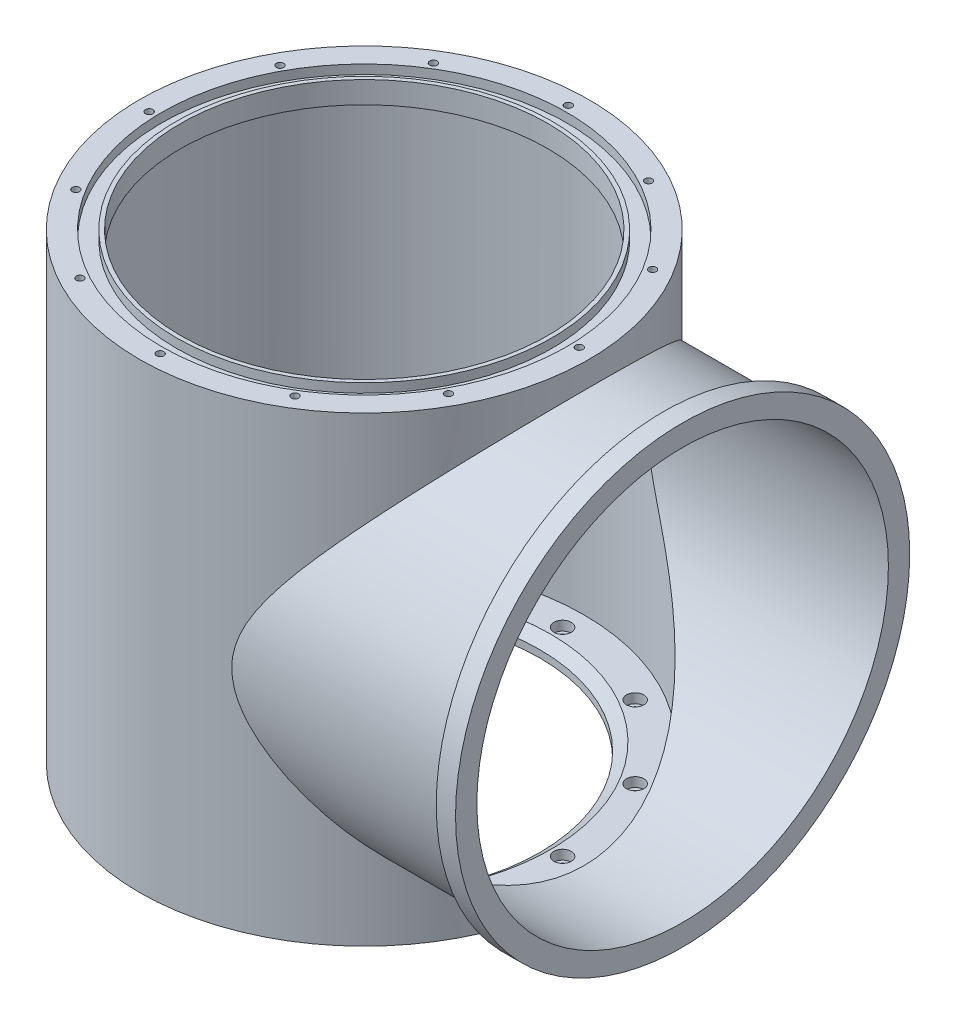
from build123d import *

# Parameters (mm, degrees)
SKETCH1_R                                            = 142.24
SKETCH1_R_2                                          = 139.065
BOSS_EXTRUDE1_DEPTH                                  = 292.1
SKETCH2_R                                            = 133.3373
SKETCH2_R_2                                          = 130.175
BOSS_EXTRUDE2_DEPTH                                  = 201.422
SKETCH1_3_R                                          = 139.065
CUT_EXTRUDE1_DEPTH                                   = 293.1000001
SKETCH2_2_R                                          = 130.175
CUT_EXTRUDE2_DEPTH                                   = 202.4220001
SKETCH3_R                                            = 143.66875
SKETCH3_R_2                                          = 133.3373
BOSS_EXTRUDE3_DEPTH                                  = 12.192
SKETCH5_R                                            = 139.065
SKETCH5_R_2                                          = 111.125
SKETCH5_R_3                                          = 2.9972
BOSS_EXTRUDE5_DEPTH                                  = 11.43
SKETCH4_R                                            = 139.065
SKETCH4_R_2                                          = 2.3368
SKETCH4_R_3                                          = 116.205
SKETCH4_R_4                                          = 128.27
SKETCH4_R_5                                          = 118.745
BOSS_EXTRUDE4_DEPTH                                  = 13.8176
SKETCH4_3_R                                          = 2.3368
CUT_EXTRUDE3_DEPTH                                   = 7.62
SKETCH4_4_R                                          = 128.27
SKETCH4_4_R_2                                        = 118.745
CUT_EXTRUDE4_DEPTH                                   = 5.7912
CBORE_FOR_M6_HEXAGON_SOCKET_HEAD_CAP_SCR_D           = 6.4
CBORE_FOR_M6_HEXAGON_SOCKET_HEAD_CAP_SCR_DEPTH       = 11.83005
CBORE_FOR_M6_HEXAGON_SOCKET_HEAD_CAP_SCR_CBORE_D     = 11
CBORE_FOR_M6_HEXAGON_SOCKET_HEAD_CAP_SCR_CBORE_DEPTH = 6
SKETCH7_W                                            = 1.27
SKETCH7_H                                            = 7.7216
CHAMFER1_SIZE                                        = 5.08
CHAMFER1_SIZE2                                       = 6.858
SKETCH5_3_R                                          = 116.6622
SKETCH5_3_R_2                                        = 111.125
CUT_EXTRUDE5_DEPTH                                   = 1.778


with BuildPart() as part:
    # Sketch1 → Boss-Extrude1 (new body)
    with BuildSketch(Plane(origin=(0, 0, 0), x_dir=(1, 0, 0), z_dir=(0, 1, 0))):
        with Locations(Location((0, 0, 0), (0, 0, 270))):  # turned: the seam where the file's is
            Circle(SKETCH1_R)
        with Locations(Location((0, 0, 0), (0, 0, 270))):  # turned: the seam where the file's is
            Circle(SKETCH1_R_2, mode=Mode.SUBTRACT)
    extrude(amount=BOSS_EXTRUDE1_DEPTH)

    # Sketch2 → Boss-Extrude2 (add)
    with BuildSketch(Plane(origin=(0, 0, 0), x_dir=(0, 0, -1), z_dir=(1, 0, 0))):
        with Locations(Location((0, 143.2687, 0), (0, 0, 180))):  # turned: the seam where the file's is
            Circle(SKETCH2_R)
        with Locations(Location((0, 143.2687, 0), (0, 0, 180))):  # turned: the seam where the file's is
            Circle(SKETCH2_R_2, mode=Mode.SUBTRACT)
    extrude(amount=BOSS_EXTRUDE2_DEPTH)

    # Sketch1_3 → Cut-Extrude1 (cut, through all)
    with BuildSketch(Plane(origin=(0, 0, 0), x_dir=(1, 0, 0), z_dir=(0, 1, 0))):
        with Locations(Location((0, 0, 0), (0, 0, 270))):  # turned: the seam where the file's is
            Circle(SKETCH1_3_R)
    extrude(amount=CUT_EXTRUDE1_DEPTH, mode=Mode.SUBTRACT)

    # Sketch2_2 → Cut-Extrude2 (cut, through all)
    with BuildSketch(Plane(origin=(0, 0, 0), x_dir=(0, 0, -1), z_dir=(1, 0, 0))):
        with Locations(Location((0, 143.2687, 0), (0, 0, 180))):  # turned: the seam where the file's is
            Circle(SKETCH2_2_R)
    extrude(amount=CUT_EXTRUDE2_DEPTH, mode=Mode.SUBTRACT)

    # Sketch3 → Boss-Extrude3 (add)
    with BuildSketch(Plane(origin=(201.422, 0, 0), x_dir=(0, 0, -1), z_dir=(1, 0, 0))):
        with Locations((0, 143.2687)):
            Circle(SKETCH3_R)
        with Locations(Location((0, 143.2687, 0), (0, 0, 180))):  # turned: the seam where the file's is
            Circle(SKETCH3_R_2, mode=Mode.SUBTRACT)
    extrude(amount=-BOSS_EXTRUDE3_DEPTH)

    # Sketch5 → Boss-Extrude5 (add)
    with BuildSketch(Plane.XZ):
        with Locations(Location((0, 0, 0), (0, 0, 270))):  # turned: the seam where the file's is
            Circle(SKETCH5_R)
        with Locations(Location((0, 0, 0), (0, 0, 270))):  # turned: the seam where the file's is
            Circle(SKETCH5_R_2, mode=Mode.SUBTRACT)
        with Locations(Location((125.476, 0, 0), (0, 0, 270))):  # turned: the seam where the file's is
            Circle(SKETCH5_R_3, mode=Mode.SUBTRACT)
        with Locations(Location((108.665403565, -62.738, 0), (0, 0, 270))):  # turned: the seam where the file's is
            Circle(SKETCH5_R_3, mode=Mode.SUBTRACT)
        with Locations(Location((62.738, -108.665403565, 0), (0, 0, 270))):  # turned: the seam where the file's is
            Circle(SKETCH5_R_3, mode=Mode.SUBTRACT)
        with Locations(Location((0, -125.476, 0), (0, 0, 270))):  # turned: the seam where the file's is
            Circle(SKETCH5_R_3, mode=Mode.SUBTRACT)
        with Locations(Location((-62.738, -108.665403565, 0), (0, 0, 270))):  # turned: the seam where the file's is
            Circle(SKETCH5_R_3, mode=Mode.SUBTRACT)
        with Locations(Location((-108.665403565, -62.738, 0), (0, 0, 270))):  # turned: the seam where the file's is
            Circle(SKETCH5_R_3, mode=Mode.SUBTRACT)
        with Locations(Location((-125.476, 0, 0), (0, 0, 270))):  # turned: the seam where the file's is
            Circle(SKETCH5_R_3, mode=Mode.SUBTRACT)
        with Locations(Location((-108.665403565, 62.738, 0), (0, 0, 270))):  # turned: the seam where the file's is
            Circle(SKETCH5_R_3, mode=Mode.SUBTRACT)
        with Locations(Location((-62.738, 108.665403565, 0), (0, 0, 270))):  # turned: the seam where the file's is
            Circle(SKETCH5_R_3, mode=Mode.SUBTRACT)
        with Locations(Location((0, 125.476, 0), (0, 0, 270))):  # turned: the seam where the file's is
            Circle(SKETCH5_R_3, mode=Mode.SUBTRACT)
        with Locations(Location((62.738, 108.665403565, 0), (0, 0, 270))):  # turned: the seam where the file's is
            Circle(SKETCH5_R_3, mode=Mode.SUBTRACT)
        with Locations(Location((108.665403565, 62.738, 0), (0, 0, 270))):  # turned: the seam where the file's is
            Circle(SKETCH5_R_3, mode=Mode.SUBTRACT)
    extrude(amount=-BOSS_EXTRUDE5_DEPTH)

    # Sketch4 → Boss-Extrude4 (add)
    with BuildSketch(Plane(origin=(0, 292.1, 0), x_dir=(1, 0, 0), z_dir=(0, 1, 0))):
        with Locations(Location((0, 0, 0), (0, 0, 90))):  # turned: the seam where the file's is
            Circle(SKETCH4_R)
        with Locations((113.088606752, 69.300787348)):
            Circle(SKETCH4_R_2, mode=Mode.SUBTRACT)
        with Locations((63.287212652, 116.560545721)):
            Circle(SKETCH4_R_2, mode=Mode.SUBTRACT)
        with Locations((-3.471938969, 132.588)):
            Circle(SKETCH4_R_2, mode=Mode.SUBTRACT)
        with Locations((-69.300787348, 113.088606752)):
            Circle(SKETCH4_R_2, mode=Mode.SUBTRACT)
        with Locations((-116.560545721, 63.287212652)):
            Circle(SKETCH4_R_2, mode=Mode.SUBTRACT)
        with Locations((-132.588, -3.471938969)):
            Circle(SKETCH4_R_2, mode=Mode.SUBTRACT)
        with Locations((-113.088606752, -69.300787348)):
            Circle(SKETCH4_R_2, mode=Mode.SUBTRACT)
        with Locations((-63.287212652, -116.560545721)):
            Circle(SKETCH4_R_2, mode=Mode.SUBTRACT)
        with Locations((3.471938969, -132.588)):
            Circle(SKETCH4_R_2, mode=Mode.SUBTRACT)
        with Locations((69.300787348, -113.088606752)):
            Circle(SKETCH4_R_2, mode=Mode.SUBTRACT)
        with Locations((116.560545721, -63.287212652)):
            Circle(SKETCH4_R_2, mode=Mode.SUBTRACT)
        with Locations((132.588, 3.471938969)):
            Circle(SKETCH4_R_2, mode=Mode.SUBTRACT)
        with Locations(Location((0, 0, 0), (0, 0, 270))):  # turned: the seam where the file's is
            Circle(SKETCH4_R_3, mode=Mode.SUBTRACT)
        with Locations((-116.560545721, 63.287212652)):
            Circle(SKETCH4_R_2)
        with Locations((-3.471938969, 132.588)):
            Circle(SKETCH4_R_2)
        with Locations((63.287212652, 116.560545721)):
            Circle(SKETCH4_R_2)
        with Locations((132.588, 3.471938969)):
            Circle(SKETCH4_R_2)
        with Locations((-132.588, -3.471938969)):
            Circle(SKETCH4_R_2)
        with Locations((-63.287212652, -116.560545721)):
            Circle(SKETCH4_R_2)
        with Locations((3.471938969, -132.588)):
            Circle(SKETCH4_R_2)
        with Locations((116.560545721, -63.287212652)):
            Circle(SKETCH4_R_2)
        Circle(SKETCH4_R_4)
        Circle(SKETCH4_R_5, mode=Mode.SUBTRACT)
        Circle(SKETCH4_R_5)
        with Locations(Location((0, 0, 0), (0, 0, 270))):  # turned: the seam where the file's is
            Circle(SKETCH4_R_3, mode=Mode.SUBTRACT)
        with Locations((69.300787348, -113.088606752)):
            Circle(SKETCH4_R_2)
        with Locations((-113.088606752, -69.300787348)):
            Circle(SKETCH4_R_2)
        with Locations((113.088606752, 69.300787348)):
            Circle(SKETCH4_R_2)
        with Locations((-69.300787348, 113.088606752)):
            Circle(SKETCH4_R_2)
    extrude(amount=-BOSS_EXTRUDE4_DEPTH)

    # Sketch4_3 → Cut-Extrude3 (cut)
    with BuildSketch(Plane(origin=(0, 292.1, 0), x_dir=(1, 0, 0), z_dir=(0, 1, 0))):
        with Locations(Location((-116.560545721, 63.287212652, 0), (0, 0, 270))):  # turned: the seam where the file's is
            Circle(SKETCH4_3_R)
        with Locations(Location((-69.300787348, 113.088606752, 0), (0, 0, 270))):  # turned: the seam where the file's is
            Circle(SKETCH4_3_R)
        with Locations(Location((-3.471938969, 132.588, 0), (0, 0, 270))):  # turned: the seam where the file's is
            Circle(SKETCH4_3_R)
        with Locations(Location((63.287212652, 116.560545721, 0), (0, 0, 270))):  # turned: the seam where the file's is
            Circle(SKETCH4_3_R)
        with Locations(Location((113.088606752, 69.300787348, 0), (0, 0, 270))):  # turned: the seam where the file's is
            Circle(SKETCH4_3_R)
        with Locations(Location((132.588, 3.471938969, 0), (0, 0, 270))):  # turned: the seam where the file's is
            Circle(SKETCH4_3_R)
        with Locations(Location((116.560545721, -63.287212652, 0), (0, 0, 270))):  # turned: the seam where the file's is
            Circle(SKETCH4_3_R)
        with Locations(Location((69.300787348, -113.088606752, 0), (0, 0, 270))):  # turned: the seam where the file's is
            Circle(SKETCH4_3_R)
        with Locations(Location((3.471938969, -132.588, 0), (0, 0, 270))):  # turned: the seam where the file's is
            Circle(SKETCH4_3_R)
        with Locations(Location((-63.287212652, -116.560545721, 0), (0, 0, 270))):  # turned: the seam where the file's is
            Circle(SKETCH4_3_R)
        with Locations(Location((-113.088606752, -69.300787348, 0), (0, 0, 270))):  # turned: the seam where the file's is
            Circle(SKETCH4_3_R)
        with Locations(Location((-132.588, -3.471938969, 0), (0, 0, 270))):  # turned: the seam where the file's is
            Circle(SKETCH4_3_R)
    extrude(amount=-CUT_EXTRUDE3_DEPTH, mode=Mode.SUBTRACT)

    # Sketch4_4 → Cut-Extrude4 (cut)
    with BuildSketch(Plane(origin=(0, 292.1, 0), x_dir=(1, 0, 0), z_dir=(0, 1, 0))):
        with Locations(Location((0, 0, 0), (0, 0, 270))):  # turned: the seam where the file's is
            Circle(SKETCH4_4_R)
        with Locations(Location((0, 0, 0), (0, 0, 270))):  # turned: the seam where the file's is
            Circle(SKETCH4_4_R_2, mode=Mode.SUBTRACT)
    extrude(amount=-CUT_EXTRUDE4_DEPTH, mode=Mode.SUBTRACT)

    # CBORE for M6 Hexagon Socket Head Cap Scr
    with Locations(Plane(origin=(125.476, 11.43, 0), x_dir=(0, 0, 1), z_dir=(0, 1, 0))):
        with Locations((0, 0), (62.738, -16.810596435), (108.665403565, -62.738), (125.476, -125.476), (108.665403565, -188.214), (62.738, -234.141403565), (0, -250.952), (-62.738, -234.141403565), (-108.665403565, -188.214), (-125.476, -125.476), (-108.665403565, -62.738), (-62.738, -16.810596435)):
            CounterBoreHole(CBORE_FOR_M6_HEXAGON_SOCKET_HEAD_CAP_SCR_D / 2, CBORE_FOR_M6_HEXAGON_SOCKET_HEAD_CAP_SCR_CBORE_D / 2, CBORE_FOR_M6_HEXAGON_SOCKET_HEAD_CAP_SCR_CBORE_DEPTH, depth=CBORE_FOR_M6_HEXAGON_SOCKET_HEAD_CAP_SCR_DEPTH)

    # Sketch7 → Cut-Revolve1 (revolve, cut)
    with BuildSketch(Plane.XY):
        with Locations((189.865, 280.5303)):
            Rectangle(SKETCH7_W, SKETCH7_H)
    revolve(axis=Axis((201.422, 143.2687, 0), (-1, 0, 0)), mode=Mode.SUBTRACT)

    # Chamfer1
    chamfer1_edges = [part.edges().sort_by_distance(p)[0] for p in [
        (0, 11.43, 111.125),
    ]]
    chamfer1_side = [part.faces().sort_by_distance(p)[0] for p in [
        (0, 5.715, 111.125),
    ]]
    chamfer(chamfer1_edges, length=CHAMFER1_SIZE, length2=CHAMFER1_SIZE2, reference=chamfer1_side[0])

    # Sketch5_3 → Cut-Extrude5 (cut)
    with BuildSketch(Plane.XZ):
        with Locations(Location((0, 0, 0), (0, 0, 270))):  # turned: the seam where the file's is
            Circle(SKETCH5_3_R)
        with Locations(Location((0, 0, 0), (0, 0, 270))):  # turned: the seam where the file's is
            Circle(SKETCH5_3_R_2, mode=Mode.SUBTRACT)
    extrude(amount=-CUT_EXTRUDE5_DEPTH, mode=Mode.SUBTRACT)


solid = part.part
